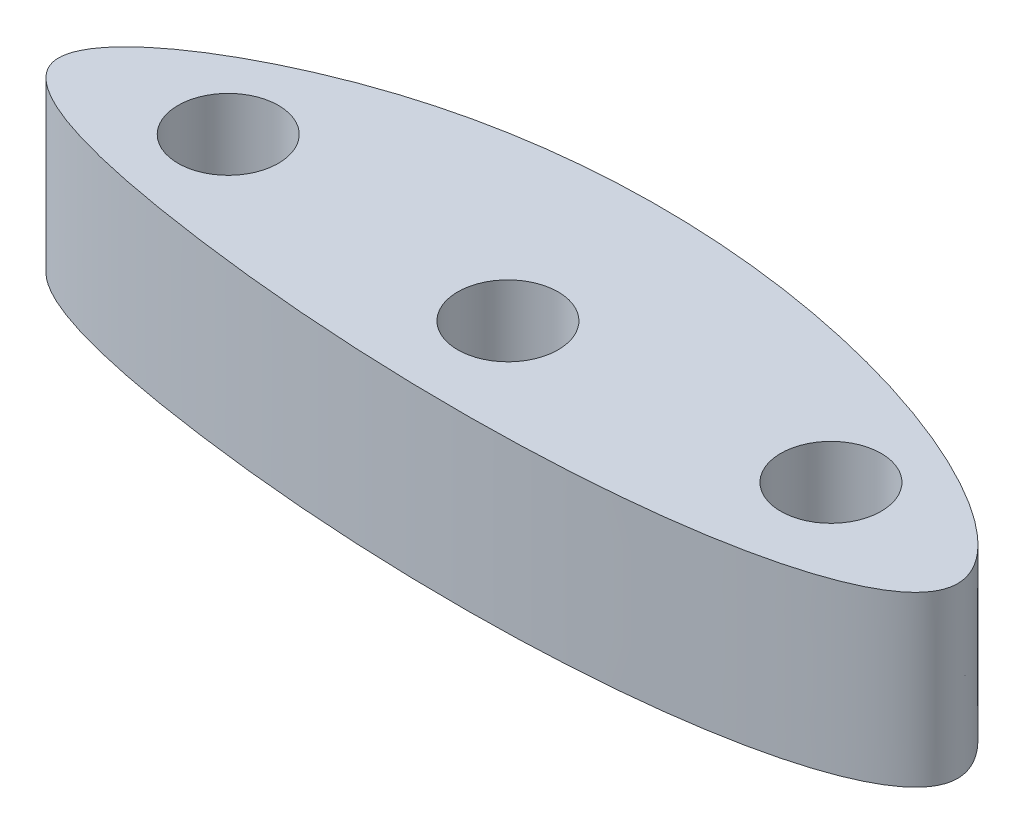
from build123d import *

# Parameters (mm, degrees)
SKETCH1_R           = 2.5
BOSS_EXTRUDE1_DEPTH = 8.4


with BuildPart() as part:
    # Sketch1 → Boss-Extrude1 (new body)
    with BuildSketch(Plane(origin=(0, 0, 0), x_dir=(1, 0, 0), z_dir=(0, 1, 0))):
        with BuildLine():
            add(Edge.make_bspline(
                [(-10.240354905, 0), (-10.757111925, 2.241146541), (9.045790116, 14.85613588), (53.602069334, -2.823636103), (10.22053594, -6.785546854), (-9.79019557, -1.952316076), (-10.240354905, 0)],
                knots=[0, 0, 0, 0, 0.133640457, 0.511482936, 0.883582619, 1, 1, 1, 1], degree=3))
        make_face()
        with Locations(Location((-2.758186563, 1.242688512, 0), (0, 0, 90))):
            Circle(SKETCH1_R, mode=Mode.SUBTRACT)
        with Locations(Location((12.241813437, 0.164766664, 0), (0, 0, 90))):
            Circle(SKETCH1_R, mode=Mode.SUBTRACT)
        with Locations(Location((27.241813437, 1.242688512, 0), (0, 0, 90))):
            Circle(SKETCH1_R, mode=Mode.SUBTRACT)
    extrude(amount=BOSS_EXTRUDE1_DEPTH)


solid = part.part
